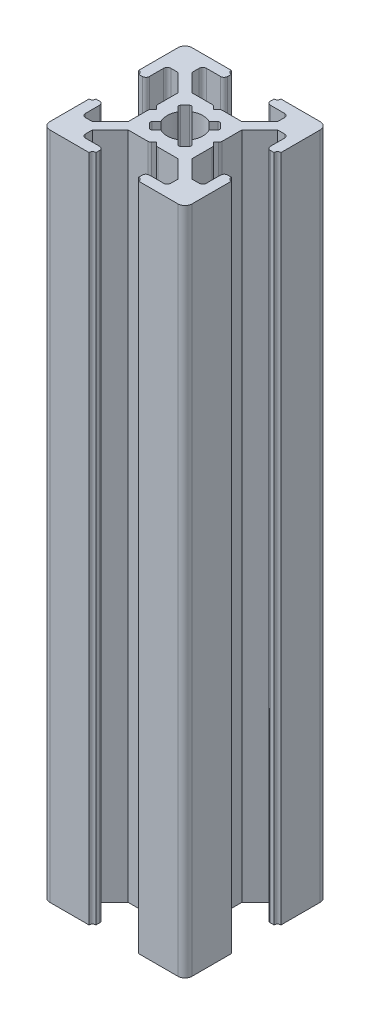
from build123d import *

# Parameters (mm, degrees)
BOSS_EXTRUDE1_DEPTH = 94
FILLET1_R           = 1
CUT_EXTRUDE1_DEPTH  = 95
FILLET2_R           = 0.5
FILLET3_R           = 0.25


with BuildPart() as part:
    # Sketch3 → Boss-Extrude1 (new body)
    with BuildSketch(Plane(origin=(0, 0, 0), x_dir=(1, 0, 0), z_dir=(0, 1, 0))):
        with BuildLine():
            Line((7, 18.5), (7, 19.5))
            ThreePointArc((7, 19.5), (6.646446609, 19.646446609), (6.5, 20))
            Line((6.5, 20), (0, 20))
            Line((0, 20), (0, 13.5))
            ThreePointArc((0, 13.5), (0.353553391, 13.353553391), (0.5, 13))
            Line((0.5, 13), (1.5, 13))
            Line((1.5, 13), (1.5, 16))
            Line((1.5, 16), (3, 16))
            Line((3, 16), (5.5, 13.5))
            Line((5.5, 13.5), (5.5, 10.5))
            Line((5.5, 10.5), (6, 10))
            Line((6, 10), (5.5, 9.5))
            Line((5.5, 9.5), (5.5, 6.5))
            Line((5.5, 6.5), (3, 4))
            Line((3, 4), (1.5, 4))
            Line((1.5, 4), (1.5, 7))
            Line((1.5, 7), (0.5, 7))
            ThreePointArc((0.5, 7), (0.353553391, 6.646446609), (0, 6.5))
            Line((0, 6.5), (0, 0))
            Line((0, 0), (6.5, 0))
            ThreePointArc((6.5, 0), (6.646446609, 0.353553391), (7, 0.5))
            Line((7, 0.5), (7, 1.5))
            Line((7, 1.5), (4, 1.5))
            Line((4, 1.5), (4, 3))
            Line((4, 3), (6.5, 5.5))
            Line((6.5, 5.5), (9.5, 5.5))
            Line((9.5, 5.5), (10, 6))
            Line((10, 6), (10.5, 5.5))
            Line((10.5, 5.5), (13.5, 5.5))
            Line((13.5, 5.5), (16, 3))
            Line((16, 3), (16, 1.5))
            Line((16, 1.5), (13, 1.5))
            Line((13, 1.5), (13, 0.5))
            ThreePointArc((13, 0.5), (13.353553391, 0.353553391), (13.5, 0))
            Line((13.5, 0), (20, 0))
            Line((20, 0), (20, 6.5))
            ThreePointArc((20, 6.5), (19.646446609, 6.646446609), (19.5, 7))
            Line((19.5, 7), (18.5, 7))
            Line((18.5, 7), (18.5, 4))
            Line((18.5, 4), (17, 4))
            Line((17, 4), (14.5, 6.5))
            Line((14.5, 6.5), (14.5, 9.5))
            Line((14.5, 9.5), (14, 10))
            Line((14, 10), (14.5, 10.5))
            Line((14.5, 10.5), (14.5, 13.5))
            Line((14.5, 13.5), (17, 16))
            Line((17, 16), (18.5, 16))
            Line((18.5, 16), (18.5, 13))
            Line((18.5, 13), (19.5, 13))
            ThreePointArc((19.5, 13), (19.646446609, 13.353553391), (20, 13.5))
            Line((20, 13.5), (20, 20))
            Line((20, 20), (13.5, 20))
            ThreePointArc((13.5, 20), (13.353553391, 19.646446609), (13, 19.5))
            Line((13, 19.5), (13, 18.5))
            Line((13, 18.5), (16, 18.5))
            Line((16, 18.5), (16, 17))
            Line((16, 17), (13.5, 14.5))
            Line((13.5, 14.5), (10.5, 14.5))
            Line((10.5, 14.5), (10, 14))
            Line((10, 14), (9.5, 14.5))
            Line((9.5, 14.5), (6.5, 14.5))
            Line((6.5, 14.5), (4, 17))
            Line((4, 17), (4, 18.5))
            Line((4, 18.5), (7, 18.5))
        make_face()
    extrude(amount=BOSS_EXTRUDE1_DEPTH)

    # Fillet1
    fillet1_edges = [part.edges().sort_by_distance(p)[0] for p in [
        (20, 47, 0),
        (0, 47, 0),
        (0, 47, -20),
        (20, 47, -20),
    ]]
    fillet(fillet1_edges, radius=FILLET1_R)

    # Sketch4 → Cut-Extrude1 (cut, through all)
    with BuildSketch(Plane(origin=(0, 94, 0), x_dir=(1, 0, 0), z_dir=(0, 1, 0))):
        with BuildLine():
            Line((10, 11), (11.195582496, 12.195582496))
            ThreePointArc((11.195582496, 12.195582496), (10, 12.5), (8.804417504, 12.195582496))
            Line((8.804417504, 12.195582496), (10, 11))
        make_face()
        with BuildLine():
            ThreePointArc((12.195582496, 11.195582496), (11.767766953, 11.767766953), (11.195582496, 12.195582496))
            Line((11.195582496, 12.195582496), (10, 11))
            Line((10, 11), (11, 10))
            Line((11, 10), (12.195582496, 11.195582496))
        make_face()
        with BuildLine():
            Line((9, 10), (10, 11))
            Line((10, 11), (8.804417504, 12.195582496))
            ThreePointArc((8.804417504, 12.195582496), (8.232233047, 11.767766953), (7.804417504, 11.195582496))
            Line((7.804417504, 11.195582496), (9, 10))
        make_face()
        Polygon((11, 10), (10, 11), (9, 10), (10, 9), align=None)
        with BuildLine():
            Line((7.804417504, 8.804417504), (9, 10))
            Line((9, 10), (7.804417504, 11.195582496))
            ThreePointArc((7.804417504, 11.195582496), (7.5, 10), (7.804417504, 8.804417504))
        make_face()
        with BuildLine():
            Line((10, 9), (9, 10))
            Line((9, 10), (7.804417504, 8.804417504))
            ThreePointArc((7.804417504, 8.804417504), (8.232233047, 8.232233047), (8.804417504, 7.804417504))
            Line((8.804417504, 7.804417504), (10, 9))
        make_face()
        with BuildLine():
            Line((11.195582496, 7.804417504), (10, 9))
            Line((10, 9), (8.804417504, 7.804417504))
            ThreePointArc((8.804417504, 7.804417504), (10, 7.5), (11.195582496, 7.804417504))
        make_face()
        with BuildLine():
            Line((12.195582496, 8.804417504), (11, 10))
            Line((11, 10), (10, 9))
            Line((10, 9), (11.195582496, 7.804417504))
            ThreePointArc((11.195582496, 7.804417504), (11.767766953, 8.232233047), (12.195582496, 8.804417504))
        make_face()
        with BuildLine():
            ThreePointArc((12.5, 10), (12.422700584, 10.616864556), (12.195582496, 11.195582496))
            Line((12.195582496, 11.195582496), (11, 10))
            Line((11, 10), (12.195582496, 8.804417504))
            ThreePointArc((12.195582496, 8.804417504), (12.422700584, 9.383135444), (12.5, 10))
        make_face()
        with BuildLine():
            ThreePointArc((8.804417504, 7.804417504), (8.232233047, 8.232233047), (7.804417504, 8.804417504))
            Line((7.804417504, 8.804417504), (7, 8))
            Line((7, 8), (8, 7))
            Line((8, 7), (8.804417504, 7.804417504))
        make_face()
        with BuildLine():
            Line((13, 8), (12.195582496, 8.804417504))
            ThreePointArc((12.195582496, 8.804417504), (11.767766953, 8.232233047), (11.195582496, 7.804417504))
            Line((11.195582496, 7.804417504), (12, 7))
            Line((12, 7), (13, 8))
        make_face()
        with BuildLine():
            Line((13, 12), (12, 13))
            Line((12, 13), (11.195582496, 12.195582496))
            ThreePointArc((11.195582496, 12.195582496), (11.767766953, 11.767766953), (12.195582496, 11.195582496))
            Line((12.195582496, 11.195582496), (13, 12))
        make_face()
        with BuildLine():
            ThreePointArc((7.804417504, 11.195582496), (8.232233047, 11.767766953), (8.804417504, 12.195582496))
            Line((8.804417504, 12.195582496), (8, 13))
            Line((8, 13), (7, 12))
            Line((7, 12), (7.804417504, 11.195582496))
        make_face()
    extrude(amount=-CUT_EXTRUDE1_DEPTH, mode=Mode.SUBTRACT)

    # Fillet2
    fillet2_edges = [part.edges().sort_by_distance(p)[0] for p in [
        (18.5, 47, -13),
        (18.5, 47, -16),
        (14.5, 47, -10.5),
        (14.5, 47, -9.5),
        (18.5, 47, -4),
        (18.5, 47, -7),
        (13, 47, -1.5),
        (16, 47, -1.5),
        (10.5, 47, -5.5),
        (9.5, 47, -5.5),
        (4, 47, -1.5),
        (7, 47, -1.5),
        (1.5, 47, -7),
        (1.5, 47, -4),
        (5.5, 47, -9.5),
        (5.5, 47, -10.5),
        (1.5, 47, -16),
        (1.5, 47, -13),
        (7, 47, -18.5),
        (4, 47, -18.5),
        (9.5, 47, -14.5),
        (10.5, 47, -14.5),
        (16, 47, -18.5),
        (13, 47, -18.5),
    ]]
    fillet(fillet2_edges, radius=FILLET2_R)

    # Fillet3
    fillet3_edges = [part.edges().sort_by_distance(p)[0] for p in [
        (7, 47, -12),
        (8, 47, -13),
        (12, 47, -13),
        (13, 47, -12),
        (13, 47, -8),
        (12, 47, -7),
        (8, 47, -7),
        (7, 47, -8),
    ]]
    fillet(fillet3_edges, radius=FILLET3_R)


solid = part.part
